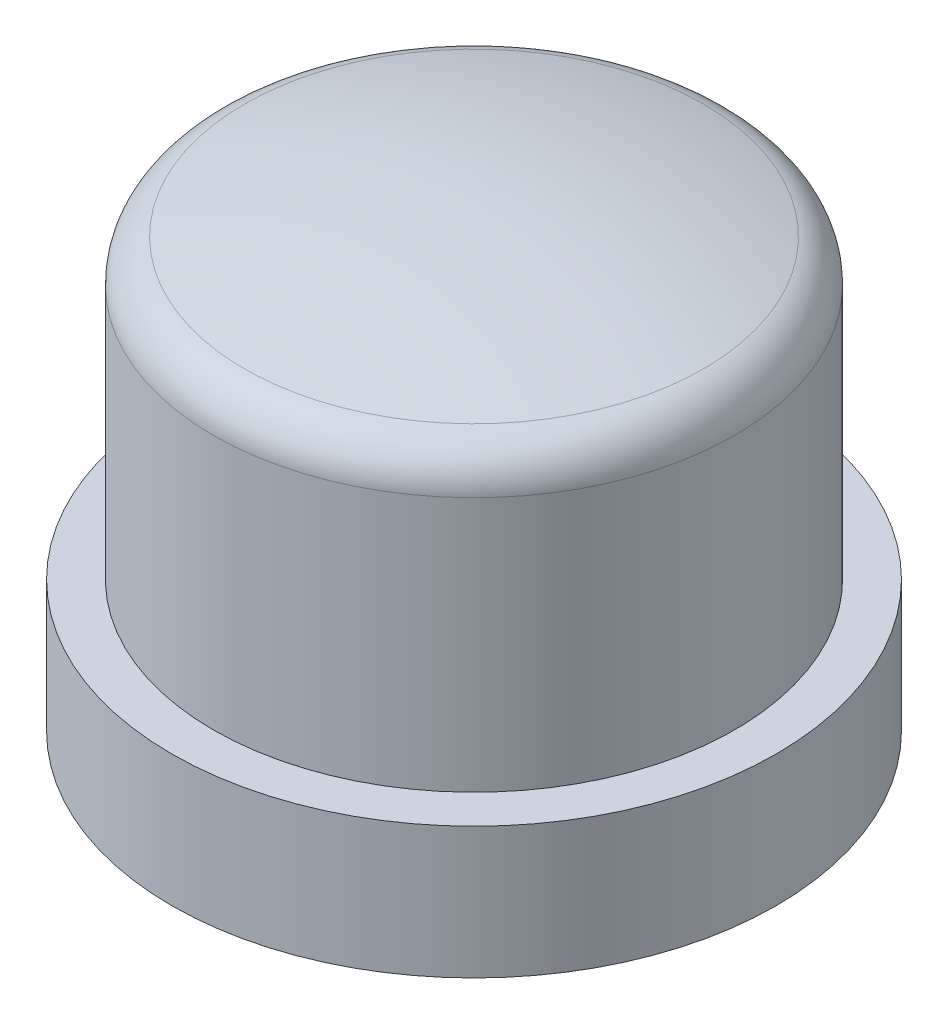
from build123d import *

# Parameters (mm, degrees)
MOVE_FACE2_BY                   = 0.025
DOME1_FACE_RADIUS               = 2.975
DOME1_HEIGHT                    = 0.5
FILLET1_R                       = 0.5
SKETCH2_R                       = 0.75
BOSS_EXTRUDE1_DEPTH             = 3.45
SKETCH3_W                       = 4
SKETCH3_H                       = 1
EXTRUDE_THIN1_DEPTH             = 3.45
MOVE_FACE1_BY                   = 0.05
BOSS_EXTRUDE2_REACH             = 8.95
SKETCH4_R                       = 2
BOSS_EXTRUDE2_DIRECTION_2_REACH = 8.95


with BuildPart() as part:
    # Sketch1 → Revolve1 (revolve)
    with BuildSketch(Plane(origin=(0, 0, 0), x_dir=(0, 0, -1), z_dir=(1, 0, 0))):
        Polygon((0, 2.236067977), (3, 2.236067977), (3, -1.039151263), (3.5, -1.039151263), (3.5, -2.539151263), (2, -2.539151263), (2, 1.236067977), (0, 1.236067977), align=None)
    revolve(axis=Axis((0, 1.236067977, 0), (0, 1, 0)))

    # Move Face2: a curved face moved inward by 0.025
    add(Solid.thicken(part.faces().sort_by_distance((0, 0.598458357, 3))[0], -MOVE_FACE2_BY), mode=Mode.SUBTRACT)

    # Dome1: a dome of height H over a round flat face of radius A is a cap of a sphere of radius (A * A + H * H) / (2 * H)
    dome1_r = (DOME1_FACE_RADIUS * DOME1_FACE_RADIUS + DOME1_HEIGHT * DOME1_HEIGHT) / (2 * DOME1_HEIGHT)
    dome1_base = Plane((0, 2.236067977, 0), z_dir=(0, 1, 0))
    with Locations(dome1_base.offset(DOME1_HEIGHT - dome1_r)):
        dome1_ball = Sphere(dome1_r, mode=Mode.PRIVATE)
    add(split(dome1_ball, bisect_by=dome1_base, keep=Keep.TOP, mode=Mode.PRIVATE))

    # Fillet1
    fillet1_edges = [part.edges().sort_by_distance(p)[0] for p in [
        (2.975, 2.236067977, 0),
    ]]
    fillet(fillet1_edges, radius=FILLET1_R)

    # Sketch2 → Boss-Extrude1 (add)
    with BuildSketch(Plane.XZ.offset(-1.236067977)):
        with Locations(Location((0, 0, 0), (0, 0, 90))):
            Circle(SKETCH2_R)
    extrude(amount=BOSS_EXTRUDE1_DEPTH)

    # Sketch3 → Extrude-Thin1 (add)
    with BuildSketch(Plane.XZ.offset(2.213932023)):
        Rectangle(SKETCH3_W, SKETCH3_H)
    extrude(amount=-EXTRUDE_THIN1_DEPTH)

    # Move Face1: a curved face moved inward by 0.05
    add(Solid.thicken(part.faces().sort_by_distance((0, -1.789151263, 3.5))[0], -MOVE_FACE1_BY), mode=Mode.SUBTRACT)

    # Sketch4 → Boss-Extrude2 (add, up to next)
    with BuildSketch(Plane.XZ.offset(2.213932023), mode=Mode.PRIVATE) as boss_extrude2_sk1:
        Circle(SKETCH4_R)
    boss_extrude2_tool1 = extrude(boss_extrude2_sk1.sketch, amount=-BOSS_EXTRUDE2_REACH, mode=Mode.PRIVATE) - part.part
    add(boss_extrude2_tool1.solids().sort_by_distance((0, -2.213932, 0))[0])
    add(boss_extrude2_tool1.solids().sort_by_distance((0, -2.213932, 0))[1])

    # Boss-Extrude2 direction 2: up to this face of the body (flat: up to its plane)
    boss_extrude2_direction_2_end = Plane(part.part.faces().sort_by_distance((0, -2.539151263, 3.352419264))[0])
    # Sketch4 → Boss-Extrude2 direction 2 (add, up to the picked face)
    with BuildSketch(Plane.XZ.offset(2.213932023), mode=Mode.PRIVATE) as boss_extrude2_direction_2_sk1:
        Circle(SKETCH4_R)
    boss_extrude2_direction_2_tool1 = split(extrude(boss_extrude2_direction_2_sk1.sketch, amount=BOSS_EXTRUDE2_DIRECTION_2_REACH, mode=Mode.PRIVATE), bisect_by=boss_extrude2_direction_2_end, keep=Keep.BOTH, mode=Mode.PRIVATE)
    add(boss_extrude2_direction_2_tool1.solids().sort_by(Axis((0, -2.213932, 0), (0, -1, 0)))[0])


solid = part.part
